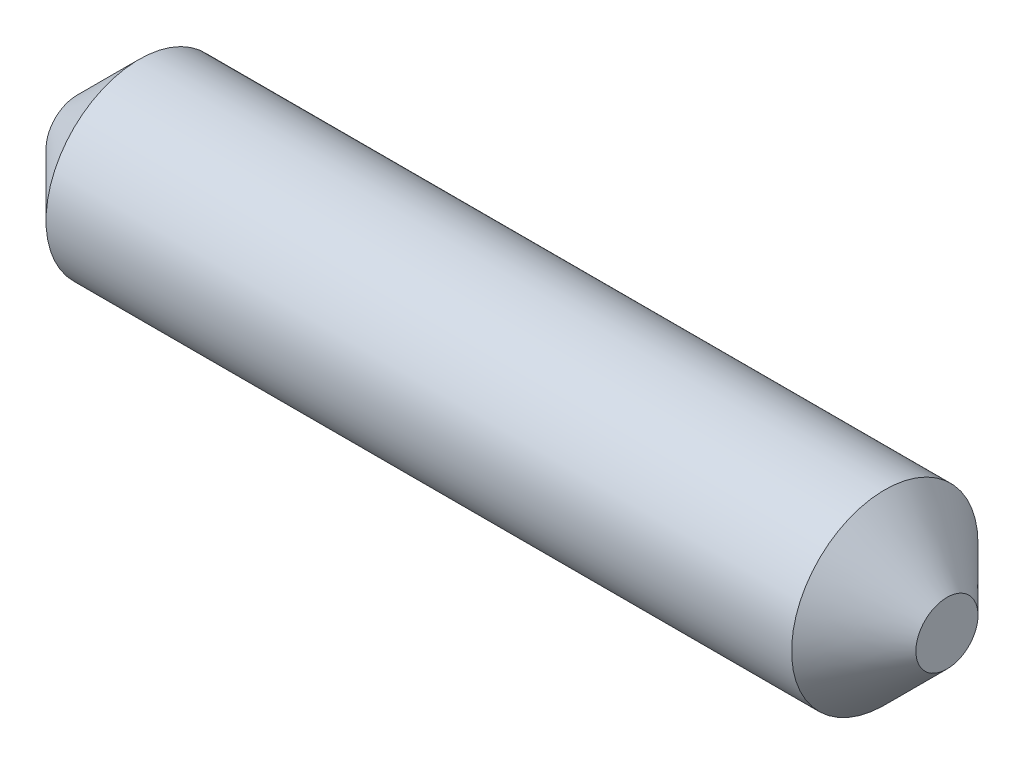
from build123d import *

# Parameters (mm, degrees)
SZKIC1_R                    = 1.5
DODANIE_WYCI_GNI_CIE1_DEPTH = 7
SFAZOWANIE1_SIZE            = 1


with BuildPart() as part:
    # Szkic1 → Dodanie-wyciągnięcie1 (new body, symmetric)
    with BuildSketch(Plane(origin=(0, 0, 0), x_dir=(0, 0, -1), z_dir=(1, 0, 0))):
        Circle(SZKIC1_R)
    extrude(amount=DODANIE_WYCI_GNI_CIE1_DEPTH, both=True)

    # Sfazowanie1
    sfazowanie1_edges = [part.edges().sort_by_distance(p)[0] for p in [
        (-7, 0, 1.5),
        (7, 0, 1.5),
    ]]
    chamfer(sfazowanie1_edges, length=SFAZOWANIE1_SIZE)


solid = part.part
